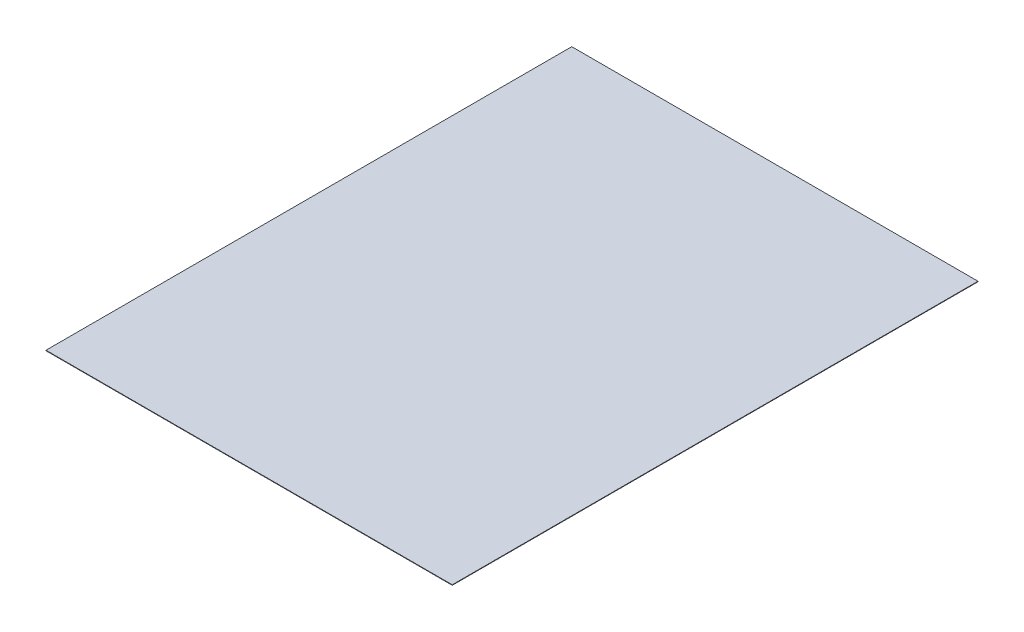
from build123d import *

# Parameters (mm, degrees)
SKETCH1_W           = 215.9
SKETCH1_H           = 279.4
BOSS_EXTRUDE1_DEPTH = 0.254


with BuildPart() as part:
    # Sketch1 → Boss-Extrude1 (new body)
    with BuildSketch(Plane(origin=(0, 0, 0), x_dir=(1, 0, 0), z_dir=(0, 1, 0))):
        with Locations((107.95, 139.7)):
            Rectangle(SKETCH1_W, SKETCH1_H)
    extrude(amount=BOSS_EXTRUDE1_DEPTH)


solid = part.part
